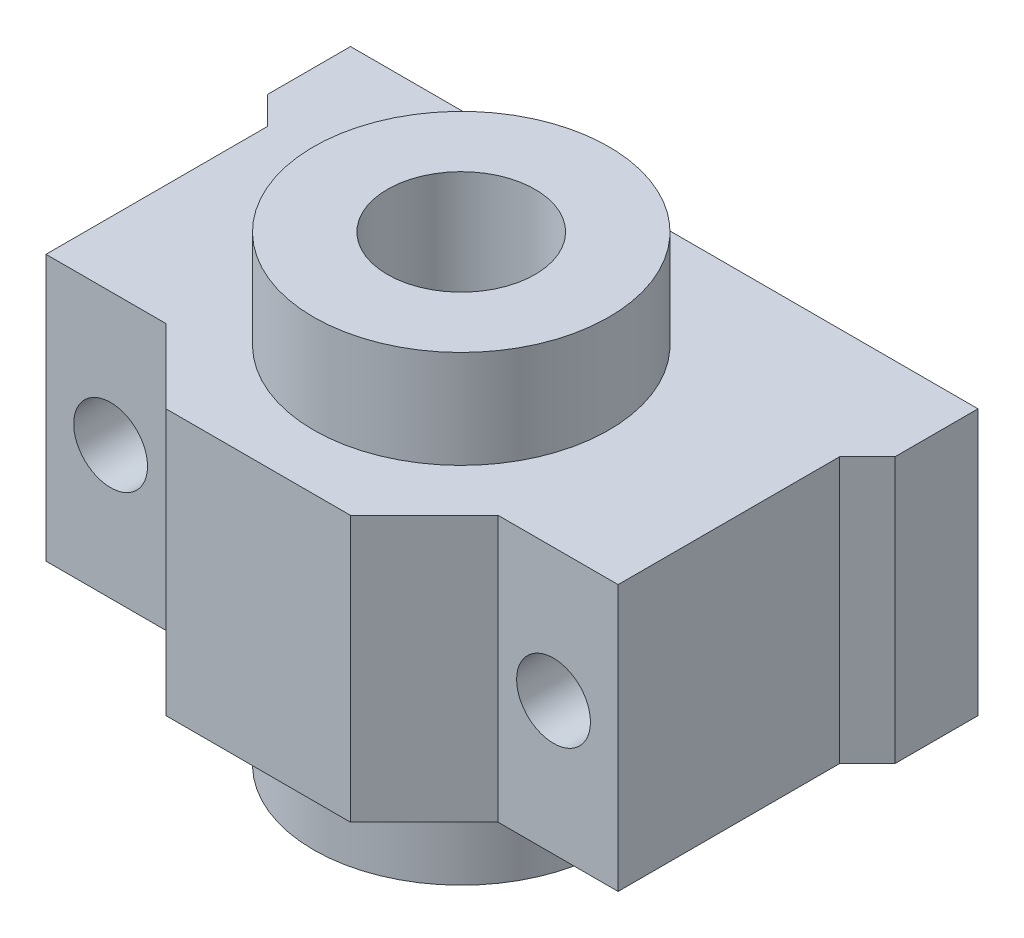
from build123d import *

# Parameters (mm, degrees)
SKETCH_1_R               = 8
SKETCH_1_R_2             = 4
EXTRUDE_1_DEPTH          = 12.5
SKETCH_2_W               = 34
SKETCH_2_H               = 22
SKETCH_2_R               = 8
EXTRUDE_2_DEPTH          = 7.2
CUT_EXTRUDE_1_DEPTH      = 13.5
CUT_EXTRUDE_1_DEPTH_BACK = 13.5
SKETCH_4_OUTSIDE_W       = 45.518
SKETCH_4_OUTSIDE_H       = 36.518
SKETCH_4_OUTSIDE_R       = 2
CUT_EXTRUDE_2_DEPTH      = 1
CUT_EXTRUDE_2_DEPTH_BACK = 29.411764706


with BuildPart() as part:
    # 草图1 → 凸台-拉伸1 (new body, symmetric)
    with BuildSketch(Plane(origin=(0, 0, 0), x_dir=(1, 0, 0), z_dir=(0, 1, 0))):
        with Locations((-68.470588235, 17.411764706)):
            Circle(SKETCH_1_R)
        with Locations((-68.470588235, 17.411764706)):
            Circle(SKETCH_1_R_2, mode=Mode.SUBTRACT)
    extrude(amount=EXTRUDE_1_DEPTH, both=True)

    # 草图2 → 凸台-拉伸2 (add, symmetric)
    with BuildSketch(Plane(origin=(0, 0, 0), x_dir=(1, 0, 0), z_dir=(0, 1, 0))):
        with Locations((-68.470588235, 17.411764706)):
            Rectangle(SKETCH_2_W, SKETCH_2_H)
        with Locations((-68.470588235, 17.411764706)):
            Circle(SKETCH_2_R, mode=Mode.SUBTRACT)
    extrude(amount=EXTRUDE_2_DEPTH, both=True)

    # 草图3 → 切除-拉伸1 (cut, two sides)
    with BuildSketch(Plane(origin=(0, 0, 0), x_dir=(1, 0, 0), z_dir=(0, 1, 0))) as cut_extrude_1_sk:
        Polygon((-52.970588235, 22.411764706), (-52.970588235, 10.411764706), (-59.470588235, 10.411764706), (-63.470588235, 6.411764706), (-51.470588235, 6.411764706), (-51.470588235, 23.911764706), align=None)
        Polygon((-85.470588235, 6.411764706), (-73.470588235, 6.411764706), (-77.470588235, 10.411764706), (-83.970588235, 10.411764706), (-83.970588235, 22.411764706), (-85.470588235, 23.911764706), align=None)
    extrude(amount=CUT_EXTRUDE_1_DEPTH, mode=Mode.SUBTRACT)
    extrude(cut_extrude_1_sk.sketch, amount=-CUT_EXTRUDE_1_DEPTH_BACK, mode=Mode.SUBTRACT)

    # 草图4 outside → 切除-拉伸2 (cut, two sides)
    with BuildSketch(Plane.XY) as cut_extrude_2_sk:
        with Locations((-68.471, 0)):
            Rectangle(SKETCH_4_OUTSIDE_W, SKETCH_4_OUTSIDE_H)
        Polygon((-60.470588235, 7.2), (-60.470588235, 12.5), (-76.470588235, 12.5), (-76.470588235, 7.2), (-85.470588235, 7.2), (-85.470588235, -7.2), (-76.470588235, -7.2), (-76.470588235, -12.5), (-60.470588235, -12.5), (-60.470588235, -7.2), (-51.470588235, -7.2), (-51.470588235, 7.2), align=None, mode=Mode.SUBTRACT)
        with Locations((-56.470588235, 0)):
            Circle(SKETCH_4_OUTSIDE_R)
        with Locations((-80.470588235, 0)):
            Circle(SKETCH_4_OUTSIDE_R)
    extrude(amount=CUT_EXTRUDE_2_DEPTH, mode=Mode.SUBTRACT)
    extrude(cut_extrude_2_sk.sketch, amount=-CUT_EXTRUDE_2_DEPTH_BACK, mode=Mode.SUBTRACT)


solid = part.part
